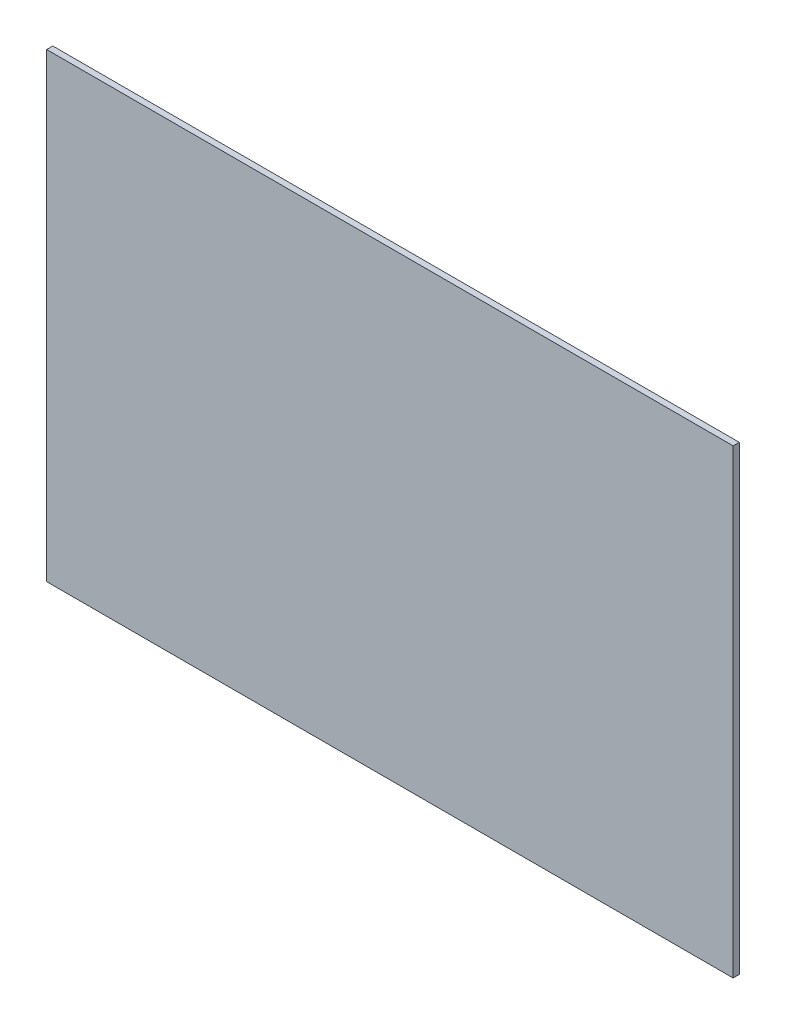
from build123d import *

# Parameters (mm, degrees)
SKETCH1_W           = 671.5125
SKETCH1_H           = 450.85
BOSS_EXTRUDE1_DEPTH = 3


with BuildPart() as part:
    # Sketch1 → Boss-Extrude1 (new body, symmetric)
    with BuildSketch(Plane.XY):
        Rectangle(SKETCH1_W, SKETCH1_H)
    extrude(amount=BOSS_EXTRUDE1_DEPTH, both=True)


solid = part.part
